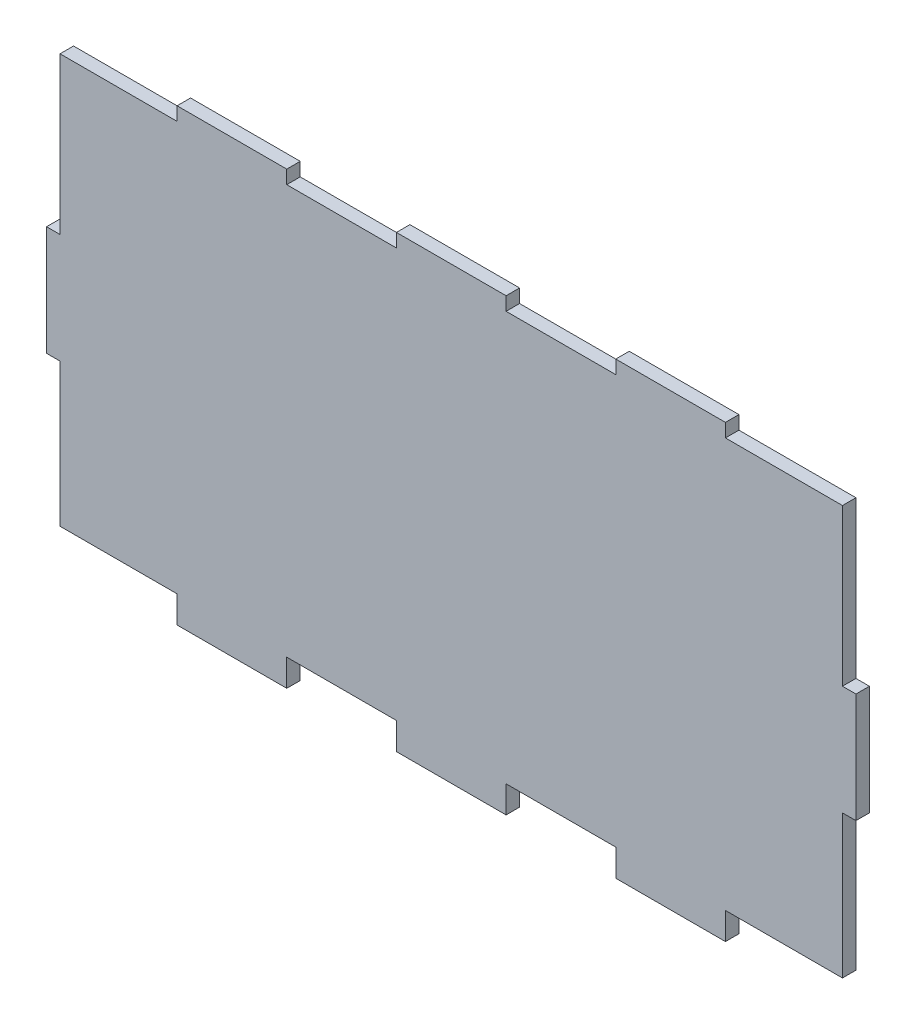
from build123d import *

# Parameters (mm, degrees)
SALIENTE_EXTRUIR1_DEPTH = 3
CROQUIS1_W              = 26.025
CROQUIS1_H              = 3
CROQUIS1_W_2            = 24.39
CORTAR_EXTRUIR1_DEPTH   = 3


with BuildPart() as part:
    # Model → Saliente-Extruir1 (new body)
    with BuildSketch(Plane.XY):
        Polygon((289, 97), (289, 62.195), (286, 62.195), (286, 37.805), (289, 37.805), (289, 13.415), (289, 3), (315.025, 3), (315.025, 0), (339.415, 0), (339.415, 3), (363.805, 3), (363.805, 0), (388.195, 0), (388.195, 3), (412.585, 3), (412.585, 0), (436.975, 0), (436.975, 3), (461.365, 3), (463, 3), (463, 37.805), (466, 37.805), (466, 62.195), (463, 62.195), (463, 86.585), (463, 97), (436.975, 97), (436.975, 100), (412.585, 100), (412.585, 97), (388.195, 97), (388.195, 100), (363.805, 100), (363.805, 97), (339.415, 97), (339.415, 100), (315.025, 100), (315.025, 97), (290.635, 97), align=None)
    extrude(amount=SALIENTE_EXTRUIR1_DEPTH)

    # Croquis1 → Cortar-Extruir1 (cut)
    with BuildSketch(Plane.XY.offset(3)):
        with Locations((302.0125, 4.5)):
            Rectangle(CROQUIS1_W, CROQUIS1_H)
        with Locations((351.61, 4.5)):
            Rectangle(CROQUIS1_W_2, CROQUIS1_H)
        with Locations((400.39, 4.5)):
            Rectangle(CROQUIS1_W_2, CROQUIS1_H)
        with Locations((449.9875, 4.5)):
            Rectangle(CROQUIS1_W, CROQUIS1_H)
    extrude(amount=-CORTAR_EXTRUIR1_DEPTH, mode=Mode.SUBTRACT)


solid = part.part
